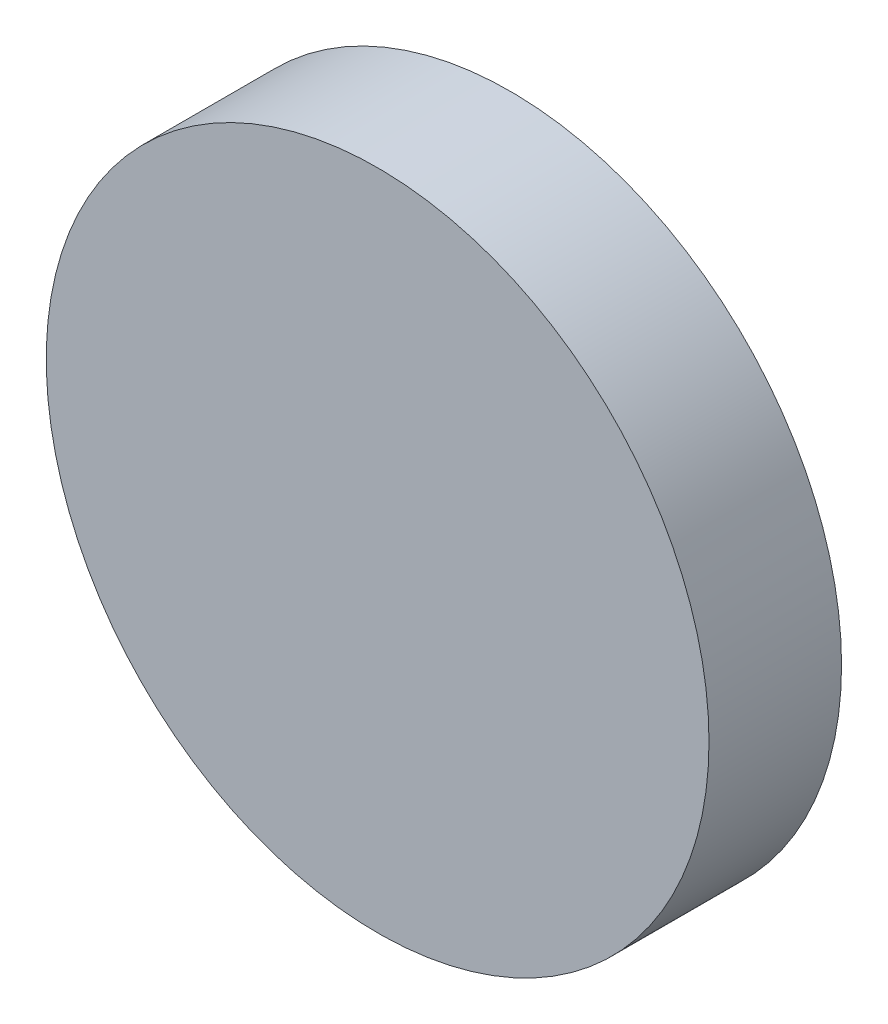
from build123d import *

# Parameters (mm, degrees)
SKETCH1_R      = 63.5
EXTRUDE1_DEPTH = 25.4


with BuildPart() as part:
    # Sketch1 → Extrude1 (new body)
    with BuildSketch(Plane.XY):
        Circle(SKETCH1_R)
    extrude(amount=EXTRUDE1_DEPTH)


solid = part.part
